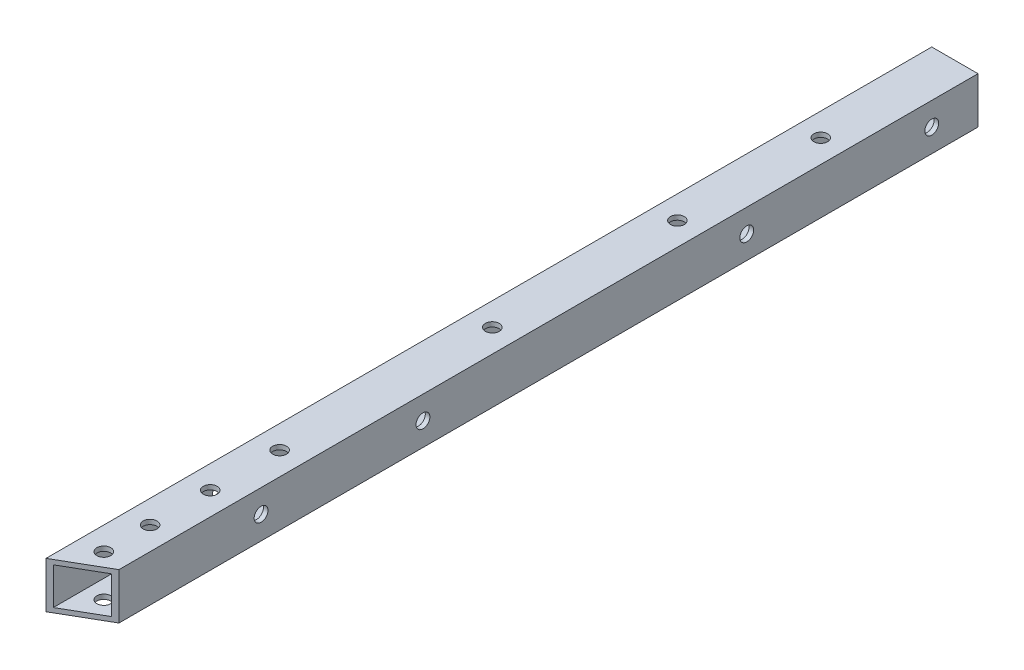
from build123d import *

# Parameters (mm, degrees)
SKETCH_1_W          = 10
SKETCH_1_H          = 10
SKETCH_1_W_2        = 8
SKETCH_1_H_2        = 8
EXTRUDE_1_DEPTH     = 191.5
SKETCH_2_R          = 1.5
CUT_EXTRUDE_1_DEPTH = 11
SKETCH_3_R          = 1.5
CUT_EXTRUDE_2_DEPTH = 11


with BuildPart() as part:
    # 草图1 → 拉伸-薄壁1 (new body)
    with BuildSketch(Plane.XY):
        Rectangle(SKETCH_1_W, SKETCH_1_H)
        Rectangle(SKETCH_1_W_2, SKETCH_1_H_2, mode=Mode.SUBTRACT)
    extrude(amount=EXTRUDE_1_DEPTH)

    # 草图2 → 切除-拉伸1 (cut, through all)
    with BuildSketch(Plane.XZ.offset(5)):
        with Locations((0, 183.994446501)):
            Circle(SKETCH_2_R)
        with Locations((0, 29)):
            Circle(SKETCH_2_R)
        with Locations((0, 173.994446501)):
            Circle(SKETCH_2_R)
        with Locations((0, 100)):
            Circle(SKETCH_2_R)
        with Locations((0, 60)):
            Circle(SKETCH_2_R)
        with Locations((0, 146)):
            Circle(SKETCH_2_R)
        with Locations((0, 161)):
            Circle(SKETCH_2_R)
        Polygon((-5, 191.5), (5, 185.726497308), (5, 191.5), align=None)
    extrude(amount=-CUT_EXTRUDE_1_DEPTH, mode=Mode.SUBTRACT)

    # 草图3 → 切除-拉伸2 (cut, through all)
    with BuildSketch(Plane.ZY.offset(5)):
        with Locations((50, 0)):
            Circle(SKETCH_3_R)
        with Locations((120, 0)):
            Circle(SKETCH_3_R)
        with Locations((10, 0)):
            Circle(SKETCH_3_R)
        with Locations((155, 0)):
            Circle(SKETCH_3_R)
    extrude(amount=-CUT_EXTRUDE_2_DEPTH, mode=Mode.SUBTRACT)


solid = part.part
